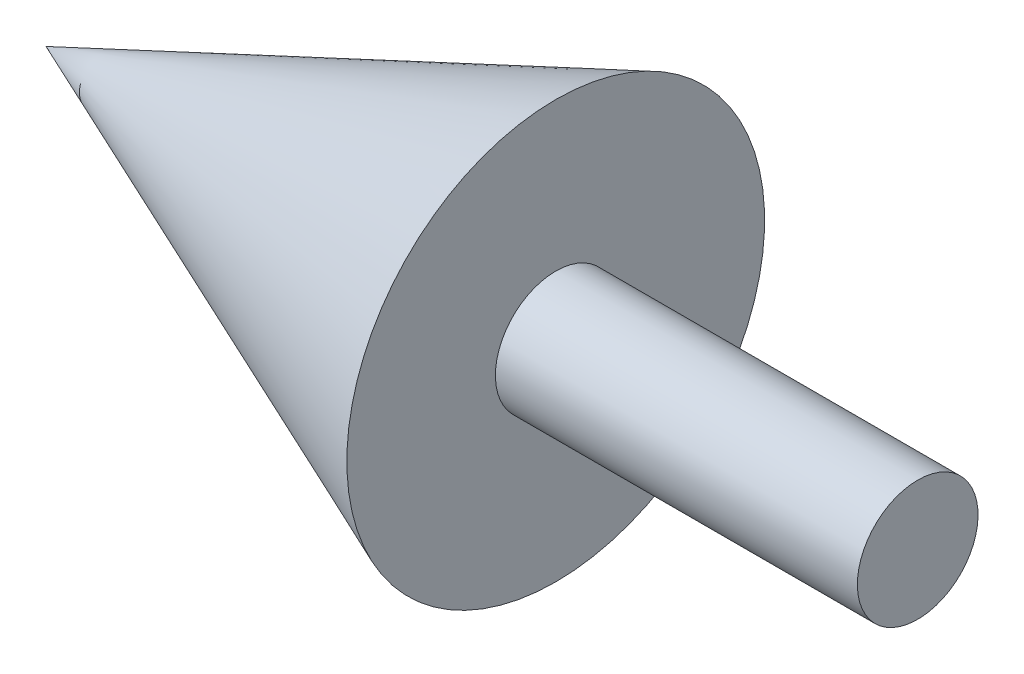
from build123d import *


with BuildPart() as part:
    # Skizze8 → Rotation3 (revolve)
    with BuildSketch(Plane.XY):
        Polygon((-12.245932067, 0), (30, 17.313301083), (30, 5), (60, 5), (60, 0), align=None)
    revolve(axis=Axis((60, 0, 0), (-1, 0, 0)))


solid = part.part
